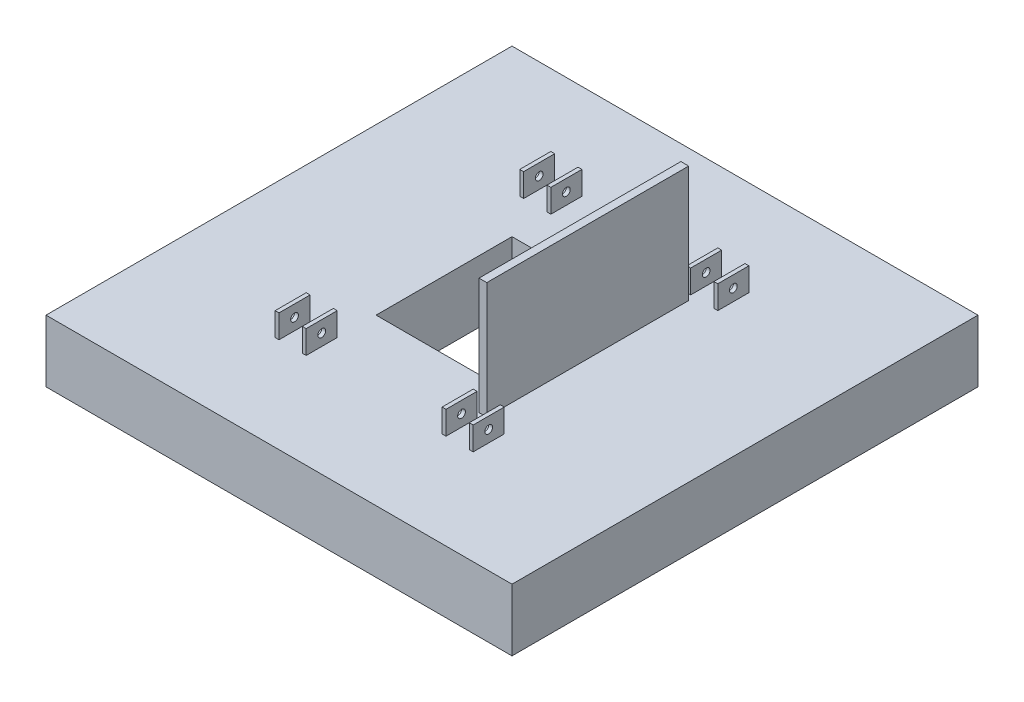
from build123d import *

# Parameters (mm, degrees)
SKETCH1_W           = 762
SKETCH1_H           = 762
BOSS_EXTRUDE1_DEPTH = 101.6
SKETCH2_W           = 222.25
SKETCH2_H           = 222.25
CUT_EXTRUDE1_DEPTH  = 102.6
SKETCH3_W           = 12.7
SKETCH3_H           = 330.2
BOSS_EXTRUDE2_DEPTH = 190.5
SKETCH4_W           = 6.35
SKETCH4_H           = 50.8
BOSS_EXTRUDE3_DEPTH = 38.1
SKETCH6_R           = 6.35
CUT_EXTRUDE2_DEPTH  = 543.925


with BuildPart() as part:
    # Sketch1 → Boss-Extrude1 (new body)
    with BuildSketch(Plane(origin=(0, 0, 0), x_dir=(1, 0, 0), z_dir=(0, 1, 0))):
        Rectangle(SKETCH1_W, SKETCH1_H)
    extrude(amount=BOSS_EXTRUDE1_DEPTH)

    # Sketch2 → Cut-Extrude1 (cut, through all)
    with BuildSketch(Plane(origin=(0, 101.6, 0), x_dir=(1, 0, 0), z_dir=(0, 1, 0))):
        Rectangle(SKETCH2_W, SKETCH2_H)
    extrude(amount=-CUT_EXTRUDE1_DEPTH, mode=Mode.SUBTRACT)

    # Sketch3 → Boss-Extrude2 (add)
    with BuildSketch(Plane(origin=(0, 101.6, 0), x_dir=(1, 0, 0), z_dir=(0, 1, 0))):
        with Locations((117.475, 0)):
            Rectangle(SKETCH3_W, SKETCH3_H)
    extrude(amount=BOSS_EXTRUDE2_DEPTH)

    # Sketch4 → Boss-Extrude3 (add)
    with BuildSketch(Plane(origin=(0, 101.6, 0), x_dir=(1, 0, 0), z_dir=(0, 1, 0))):
        with Locations((-158.75, -200.025)):
            Rectangle(SKETCH4_W, SKETCH4_H)
        with Locations((-114.3, -200.025)):
            Rectangle(SKETCH4_W, SKETCH4_H)
        with Locations((114.3, -200.025)):
            Rectangle(SKETCH4_W, SKETCH4_H)
        with Locations((158.75, -200.025)):
            Rectangle(SKETCH4_W, SKETCH4_H)
        with Locations((158.75, 200.025)):
            Rectangle(SKETCH4_W, SKETCH4_H)
        with Locations((114.3, 200.025)):
            Rectangle(SKETCH4_W, SKETCH4_H)
        with Locations((-114.3, 200.025)):
            Rectangle(SKETCH4_W, SKETCH4_H)
        with Locations((-158.75, 200.025)):
            Rectangle(SKETCH4_W, SKETCH4_H)
    extrude(amount=BOSS_EXTRUDE3_DEPTH)

    # Sketch6 → Cut-Extrude2 (cut, through all)
    with BuildSketch(Plane.ZY.offset(161.925)):
        with Locations((-200.025, 120.65)):
            Circle(SKETCH6_R)
        with Locations((200.025, 120.65)):
            Circle(SKETCH6_R)
    extrude(amount=-CUT_EXTRUDE2_DEPTH, mode=Mode.SUBTRACT)


solid = part.part
